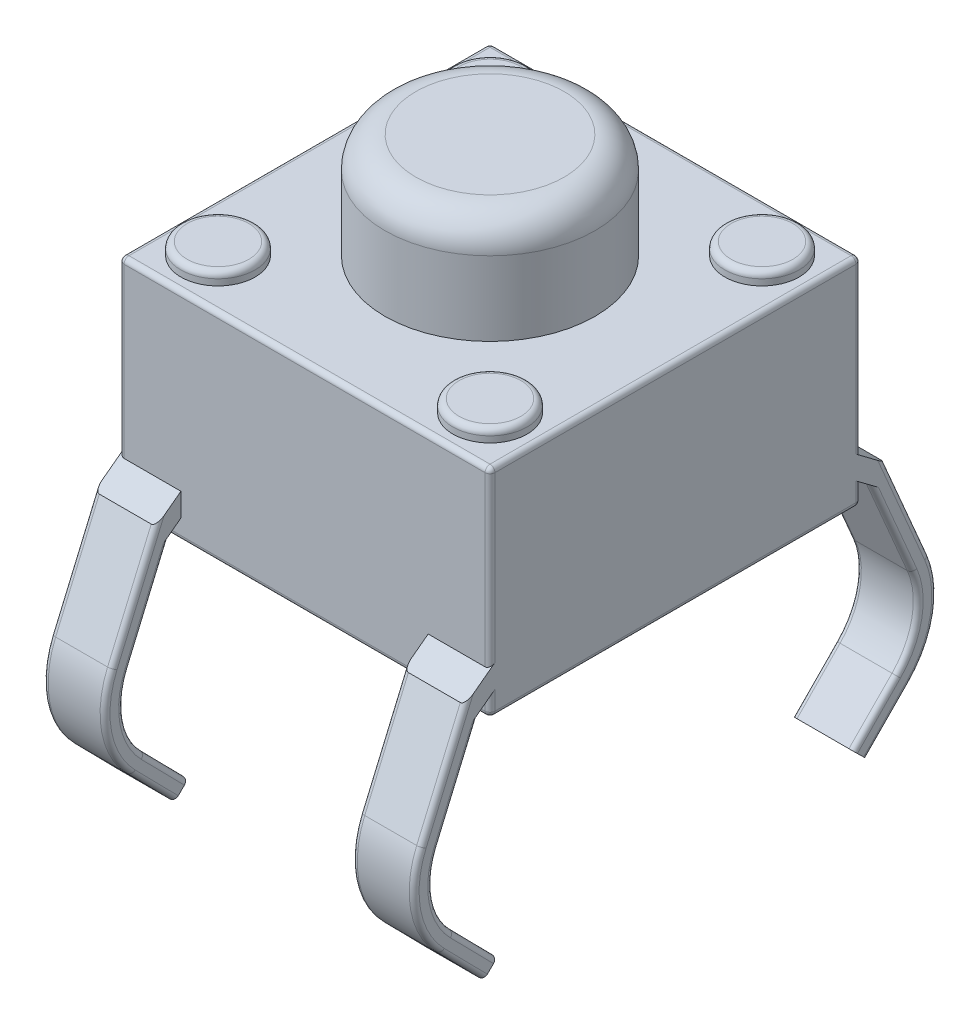
from build123d import *

# Parameters (mm, degrees)
SKETCH1_W            = 6
SKETCH1_H            = 6
BOSS_EXTRUDE1_DEPTH  = 3.5
SKETCH2_R            = 1.7
BOSS_EXTRUDE2_DEPTH  = 1.7
SKETCH3_R            = 0.6
BOSS_EXTRUDE3_DEPTH  = 0.2
EXTRUDE_THIN1_DEPTH  = 1
LPATTERN1_COUNT      = 2
LPATTERN1_PITCH      = 5
MIRROR1_COPY_1_DEPTH = 1
FILLET1_R            = 0.1
FILLET2_R            = 0.5
FILLET13_R           = 0.08


with BuildPart() as part:
    # Sketch1 → Boss-Extrude1 (new body)
    with BuildSketch(Plane(origin=(0, 0, 0), x_dir=(1, 0, 0), z_dir=(0, 1, 0))):
        with Locations((3, 3)):
            Rectangle(SKETCH1_W, SKETCH1_H)
    extrude(amount=BOSS_EXTRUDE1_DEPTH)

    # Sketch2 → Boss-Extrude2 (add)
    with BuildSketch(Plane(origin=(0, 3.5, 0), x_dir=(1, 0, 0), z_dir=(0, 1, 0))):
        with Locations((3, 3)):
            Circle(SKETCH2_R)
    extrude(amount=BOSS_EXTRUDE2_DEPTH)

    # Sketch3 → Boss-Extrude3 (add)
    with BuildSketch(Plane(origin=(0, 3.5, 0), x_dir=(1, 0, 0), z_dir=(0, 1, 0))):
        with Locations((0.8, 5.2)):
            Circle(SKETCH3_R)
        with Locations((5.2, 5.2)):
            Circle(SKETCH3_R)
        with Locations((5.2, 0.8)):
            Circle(SKETCH3_R)
        with Locations((0.8, 0.8)):
            Circle(SKETCH3_R)
    extrude(amount=BOSS_EXTRUDE3_DEPTH)

    # Sketch4 → Extrude-Thin1 (add)
    with BuildSketch(Plane(origin=(0, 0, 0), x_dir=(0, 0, -1), z_dir=(1, 0, 0))):
        with BuildLine():
            Line((6, 0.7), (6.400229577, 0.400306347))
            Line((6.400229577, 0.400306347), (7.106299541, -1.24914741))
            ThreePointArc((7.106299541, -1.24914741), (7.201399727, -2.117126527), (6.796998144, -2.891007108))
            Line((6.796998144, -2.891007108), (6.1, -3.6))
            Line((6.1, -3.6), (5.886066016, -3.389685353))
            Line((5.886066016, -3.389685353), (6.58306416, -2.680692462))
            ThreePointArc((6.58306416, -2.680692462), (6.906585426, -2.061587997), (6.830505278, -1.367204703))
            Line((6.830505278, -1.367204703), (6.15606867, 0.208350204))
            Line((6.15606867, 0.208350204), (5.820183808, 0.459862254))
            Line((5.820183808, 0.459862254), (6, 0.7))
        make_face()
    extrude_thin1 = extrude(amount=EXTRUDE_THIN1_DEPTH)

    # LPattern1: Extrude-Thin1 ×2
    with Locations(*[(i * LPATTERN1_PITCH, 0, 0) for i in range(1, LPATTERN1_COUNT)]):
        add(extrude_thin1)

    # Mirror1: Extrude-Thin1 across plane
    add(extrude_thin1.mirror(Plane.XY.offset(-3)))

    # Mirror1 copy 1 sketch → Mirror1 copy 1 (add)
    with BuildSketch(Plane(origin=(5, 0, -6), x_dir=(0, 0, 1), z_dir=(1, 0, 0))):
        with BuildLine():
            Line((6, -0.7), (6.400229577, -0.400306347))
            Line((6.400229577, -0.400306347), (7.106299541, 1.24914741))
            ThreePointArc((7.106299541, 1.24914741), (7.201399727, 2.117126527), (6.796998144, 2.891007108))
            Line((6.796998144, 2.891007108), (6.1, 3.6))
            Line((6.1, 3.6), (5.886066016, 3.389685353))
            Line((5.886066016, 3.389685353), (6.58306416, 2.680692462))
            ThreePointArc((6.58306416, 2.680692462), (6.906585426, 2.061587997), (6.830505278, 1.367204703))
            Line((6.830505278, 1.367204703), (6.15606867, -0.208350204))
            Line((6.15606867, -0.208350204), (5.820183808, -0.459862254))
            Line((5.820183808, -0.459862254), (6, -0.7))
        make_face()
    extrude(amount=MIRROR1_COPY_1_DEPTH)

    # Fillet1
    fillet1_edges = [part.edges().sort_by_distance(p)[0] for p in [
        (0.2, 3.7, -5.2),
        (4.6, 3.7, -5.2),
        (4.6, 3.7, -0.8),
        (0.2, 3.7, -0.8),
    ]]
    fillet(fillet1_edges, radius=FILLET1_R)

    # Fillet2
    fillet2_edges = [part.edges().sort_by_distance(p)[0] for p in [
        (1.3, 5.2, -3),
    ]]
    fillet(fillet2_edges, radius=FILLET2_R)

    # Fillet13
    fillet13_edges = [part.edges().sort_by_distance(p)[0] for p in [
        (6, 3.5, -3),
        (0, -0.579427249, 0.493286974),
        (0, -2.061587997, 0.906585426),
        (0, -3.035188907, 0.234565088),
        (1, -3.035188907, 0.234565088),
        (1, -2.061587997, 0.906585426),
        (1, -0.579427249, 0.493286974),
        (0, -0.424420531, 0.753264559),
        (0, -2.117126527, 1.201399727),
        (0, -3.245503554, 0.448499072),
        (6, 0.162607553, 0),
        (6, -0.424420531, 0.753264559),
        (6, -2.117126527, 1.201399727),
        (6, -3.245503554, 0.448499072),
        (5, -0.579427249, 0.493286974),
        (5, -2.061587997, 0.906585426),
        (5, -3.035188907, 0.234565088),
        (6, -3.035188907, 0.234565088),
        (6, -2.061587997, 0.906585426),
        (6, -0.579427249, 0.493286974),
        (5, -0.424420531, 0.753264559),
        (5, -2.117126527, 1.201399727),
        (5, -3.245503554, 0.448499072),
        (3, 3.5, -6),
        (0, 0.162607553, -6),
        (0, 3.5, -3),
        (1, -0.579427249, -6.493286974),
        (1, -2.061587997, -6.906585426),
        (1, -3.035188907, -6.234565088),
        (0, -0.424420531, -6.753264559),
        (0, -2.117126527, -7.201399727),
        (0, -3.245503554, -6.448499072),
        (1, -3.245503554, -6.448499072),
        (1, -2.117126527, -7.201399727),
        (1, -0.424420531, -6.753264559),
        (3, 0, -6),
        (6, 0, -3),
        (3, 0, 0),
        (0, 0, -3),
        (6, 0.162607553, -6),
        (6, -0.579427249, -6.493286974),
        (3, 3.5, 0),
        (6, -2.061587997, -6.906585426),
        (6, -3.035188907, -6.234565088),
        (5, -0.424420531, -6.753264559),
        (5, -2.117126527, -7.201399727),
        (5, -3.245503554, -6.448499072),
        (5, -3.035188907, -6.234565088),
        (6, -3.245503554, -6.448499072),
        (6, -2.117126527, -7.201399727),
        (6, -0.424420531, -6.753264559),
        (0, 2.1, -6),
        (5, -0.579427249, -6.493286974),
        (6, 2.1, -6),
        (5, -2.061587997, -6.906585426),
        (6, 2.1, 0),
        (0, 2.1, 0),
        (0, 0.162607553, 0),
        (1, -0.424420531, 0.753264559),
        (1, -2.117126527, 1.201399727),
        (1, -3.245503554, 0.448499072),
    ]]
    fillet(fillet13_edges, radius=FILLET13_R)


solid = part.part
